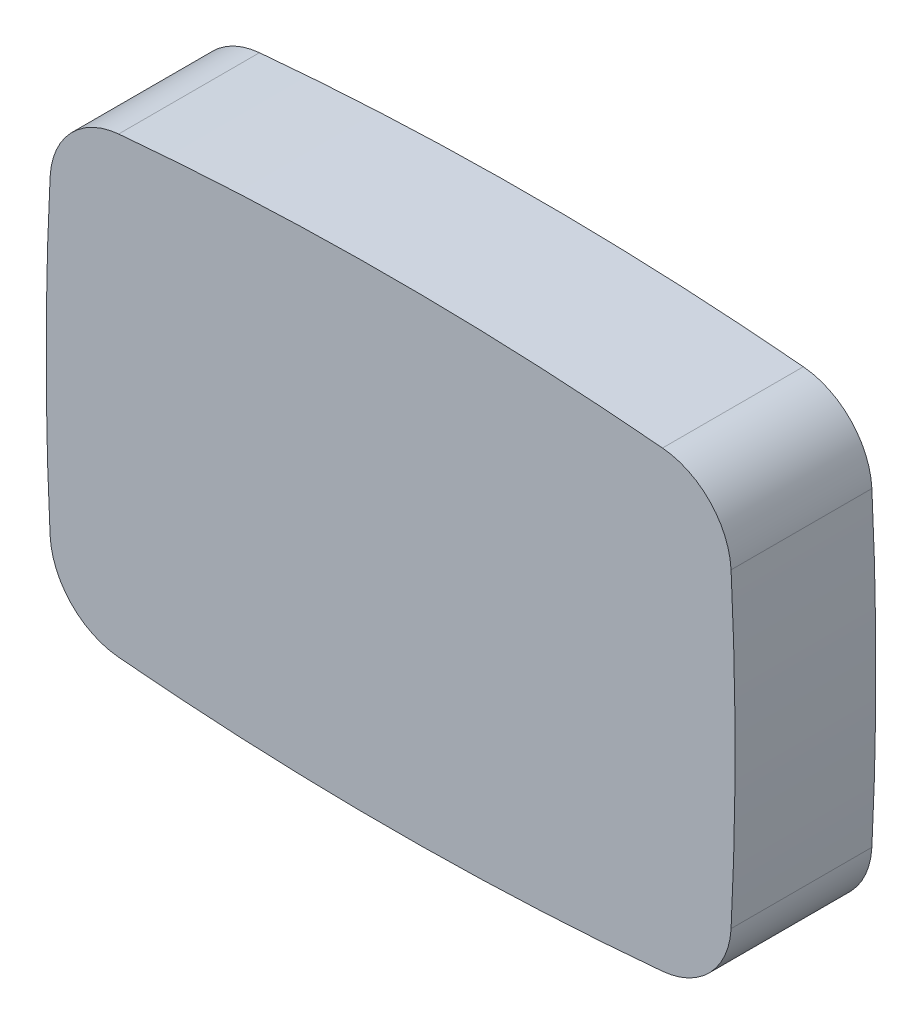
from build123d import *

# Parameters (mm, degrees)
GRUNDFORM_DEPTH = 28


with BuildPart() as part:
    # Skizze2 → Grundform (new body)
    with BuildSketch(Plane.XY):
        with BuildLine():
            ThreePointArc((54.076028974, 45.058183854), (0, 47.5), (-54.076028974, 45.058183854))
            ThreePointArc((-54.076028974, 45.058183854), (-63.534180091, 40.5184013), (-67.704234102, 30.891517187))
            ThreePointArc((-67.704234102, 30.891517187), (-68.5, 0), (-67.704234102, -30.891517187))
            ThreePointArc((-67.704234102, -30.891517187), (-63.534180091, -40.5184013), (-54.076028974, -45.058183854))
            ThreePointArc((-54.076028974, -45.058183854), (0, -47.5), (54.076028974, -45.058183854))
            ThreePointArc((54.076028974, -45.058183854), (63.534180091, -40.5184013), (67.704234102, -30.891517187))
            ThreePointArc((67.704234102, -30.891517187), (68.5, 0), (67.704234102, 30.891517187))
            ThreePointArc((67.704234102, 30.891517187), (63.534180091, 40.5184013), (54.076028974, 45.058183854))
        make_face()
    extrude(amount=GRUNDFORM_DEPTH)


solid = part.part
